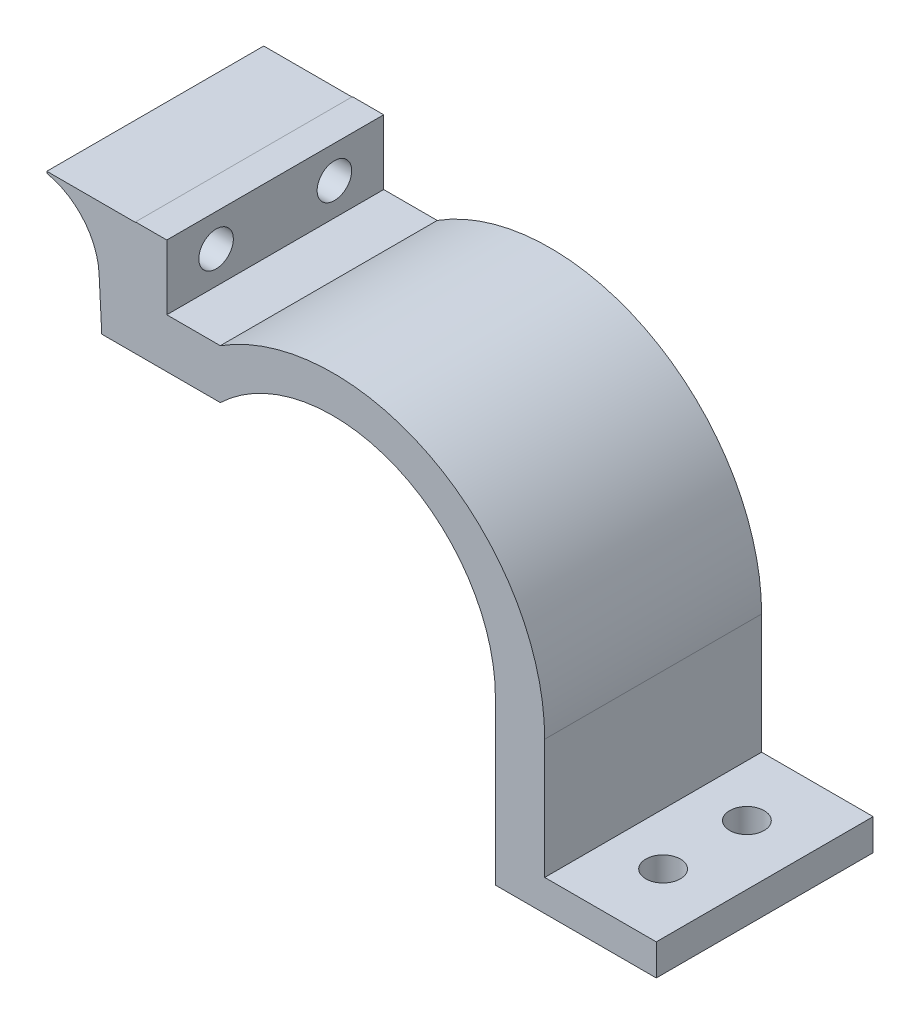
from build123d import *

# Parameters (mm, degrees)
BOSS_EXTRUDE1_DEPTH = 44
CUT_EXTRUDE1_REACH  = 8.35
SKETCH2_R           = 3.5
BOSS_EXTRUDE2_DEPTH = 44
CUT_EXTRUDE2_REACH  = 26.336
SKETCH5_R           = 3.5
SKETCH6_R           = 5
CUT_EXTRUDE3_DEPTH  = 15


with BuildPart() as part:
    # Sketch1 → Boss-Extrude1 (new body)
    with BuildSketch(Plane.XY):
        with BuildLine():
            Line((33.003348812, 0), (33.003348812, -33))
            Line((33.003348812, -33), (65.632108119, -33))
            Line((65.632108119, -33), (65.632108119, -26.65))
            Line((65.632108119, -26.65), (43.003348812, -26.65))
            Line((43.003348812, -26.65), (43.003348812, -2.369569967))
            ThreePointArc((43.003348812, -2.369569967), (20.809611253, 35.186501293), (-22.793831907, 33.859768466))
            Line((-22.793831907, 33.859768466), (-33.65, 33.859768466))
            Line((-33.65, 33.859768466), (-33.65, 46.995147616))
            Line((-33.65, 46.995147616), (-40, 46.995147616))
            Line((-40, 46.995147616), (-40, 23.859768466))
            Line((-40, 23.859768466), (-22.793831907, 23.859768466))
            ThreePointArc((-22.793831907, 23.859768466), (12.978190551, 30.342272193), (33.003348812, 0))
        make_face()
    extrude(amount=-BOSS_EXTRUDE1_DEPTH)

    # Sketch2 → Cut-Extrude1 (cut, up to next)
    with BuildSketch(Plane(origin=(0, -26.65, 0), x_dir=(1, 0, 0), z_dir=(0, 1, 0)), mode=Mode.PRIVATE) as cut_extrude1_sk1:
        with Locations((53.516422245, 13.5)):
            Circle(SKETCH2_R)
    cut_extrude1_tool1 = extrude(cut_extrude1_sk1.sketch, amount=-CUT_EXTRUDE1_REACH, mode=Mode.PRIVATE) & part.part
    add(cut_extrude1_tool1.solids().sort_by_distance((53.516422, -26.65, -13.5))[0], mode=Mode.SUBTRACT)
    # Sketch2 → Cut-Extrude1 (cut, up to next)
    with BuildSketch(Plane(origin=(0, -26.65, 0), x_dir=(1, 0, 0), z_dir=(0, 1, 0)), mode=Mode.PRIVATE) as cut_extrude1_sk2:
        with Locations((53.516422245, 30.5)):
            Circle(SKETCH2_R)
    cut_extrude1_tool2 = extrude(cut_extrude1_sk2.sketch, amount=-CUT_EXTRUDE1_REACH, mode=Mode.PRIVATE) & part.part
    add(cut_extrude1_tool2.solids().sort_by_distance((53.516422, -26.65, -30.5))[0], mode=Mode.SUBTRACT)

    # Sketch4 → Boss-Extrude2 (add)
    with BuildSketch(Plane.XY):
        with BuildLine():
            Line((-40, 23.859768466), (-46.838602468, 23.859768466))
            Line((-46.838602468, 23.859768466), (-47.380853546, 34.206535409))
            ThreePointArc((-47.380853546, 34.206535409), (-50.578394755, 42.184822071), (-57.98577318, 46.544646919))
            Line((-57.98577318, 46.544646919), (-57.98577318, 46.904796258))
            Line((-57.98577318, 46.904796258), (-47.376426292, 46.904796258))
            Line((-47.376426292, 46.904796258), (-40, 46.904796258))
            Line((-40, 46.904796258), (-40, 23.859768466))
        make_face()
    extrude(amount=-BOSS_EXTRUDE2_DEPTH)

    # Sketch5 → Cut-Extrude2 (cut, up to next)
    with BuildSketch(Plane(origin=(-33.65, 0, 0), x_dir=(0, 0, -1), z_dir=(1, 0, 0)), mode=Mode.PRIVATE) as cut_extrude2_sk1:
        with Locations((10, 40.425147616)):
            Circle(SKETCH5_R)
    cut_extrude2_tool1 = extrude(cut_extrude2_sk1.sketch, amount=-CUT_EXTRUDE2_REACH, mode=Mode.PRIVATE) & part.part
    add(cut_extrude2_tool1.solids().sort_by_distance((-33.65, 40.425148, -10))[0], mode=Mode.SUBTRACT)
    # Sketch5 → Cut-Extrude2 (cut, up to next)
    with BuildSketch(Plane(origin=(-33.65, 0, 0), x_dir=(0, 0, -1), z_dir=(1, 0, 0)), mode=Mode.PRIVATE) as cut_extrude2_sk2:
        with Locations((34, 40.425147616)):
            Circle(SKETCH5_R)
    cut_extrude2_tool2 = extrude(cut_extrude2_sk2.sketch, amount=-CUT_EXTRUDE2_REACH, mode=Mode.PRIVATE) & part.part
    add(cut_extrude2_tool2.solids().sort_by_distance((-33.65, 40.425148, -34))[0], mode=Mode.SUBTRACT)

    # Sketch6 → Cut-Extrude3 (cut)
    with BuildSketch(Plane(origin=(-58.65, 0, 0), x_dir=(0, 0, -1), z_dir=(1, 0, 0))):
        with Locations((34, 40.425147616)):
            Circle(SKETCH6_R)
        with Locations((10, 40.425147616)):
            Circle(SKETCH6_R)
    extrude(amount=CUT_EXTRUDE3_DEPTH, mode=Mode.SUBTRACT)


solid = part.part
